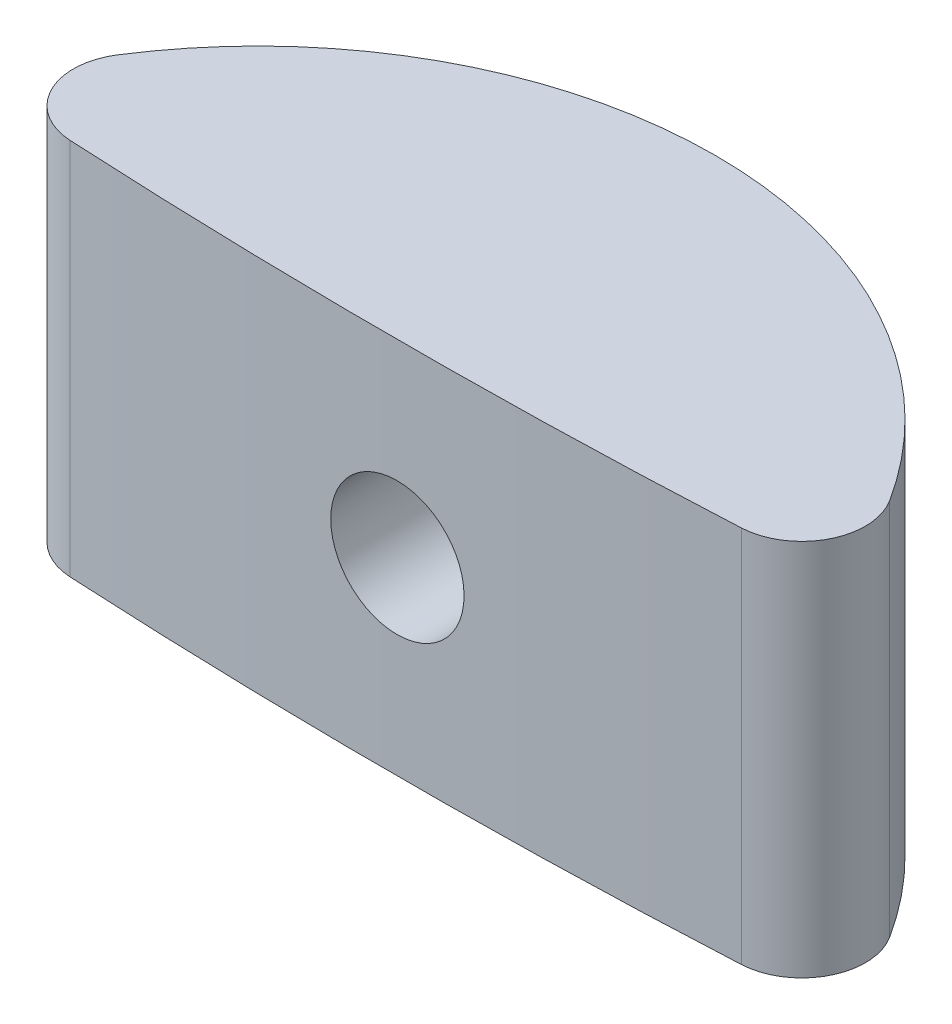
from build123d import *

# Parameters (mm, degrees)
BOSS_EXTRUDE1_DEPTH     = 4.826
CUT_EXTRUDE1_DEPTH      = 4.826
CUT_EXTRUDE1_DEPTH_BACK = 4.826
SKETCH2_R               = 0.8509


with BuildPart() as part:
    # Sketch1 → Boss-Extrude1 (new body)
    with BuildSketch(Plane(origin=(0, 0, 0), x_dir=(1, 0, 0), z_dir=(0, 1, 0))):
        with BuildLine():
            ThreePointArc((-4.285409449, -1.920000792), (0, -2.032), (4.285409449, -1.920000792))
            ThreePointArc((4.285409449, -1.920000792), (4.964968073, -1.480948711), (4.928136529, -0.672734574))
            ThreePointArc((4.928136529, -0.672734574), (0, 2.032), (-4.928136529, -0.672734574))
            ThreePointArc((-4.928136529, -0.672734574), (-4.964968073, -1.480948711), (-4.285409449, -1.920000792))
        make_face()
    extrude(amount=BOSS_EXTRUDE1_DEPTH)

    # Sketch2 → Cut-Extrude1 (cut, two sides: drawn at the far end of the back side and taken through both)
    with BuildSketch(Plane.XY.offset(-CUT_EXTRUDE1_DEPTH_BACK)):
        with Locations((0, 2.413)):
            Circle(SKETCH2_R)
    extrude(amount=CUT_EXTRUDE1_DEPTH + CUT_EXTRUDE1_DEPTH_BACK, mode=Mode.SUBTRACT)


solid = part.part
